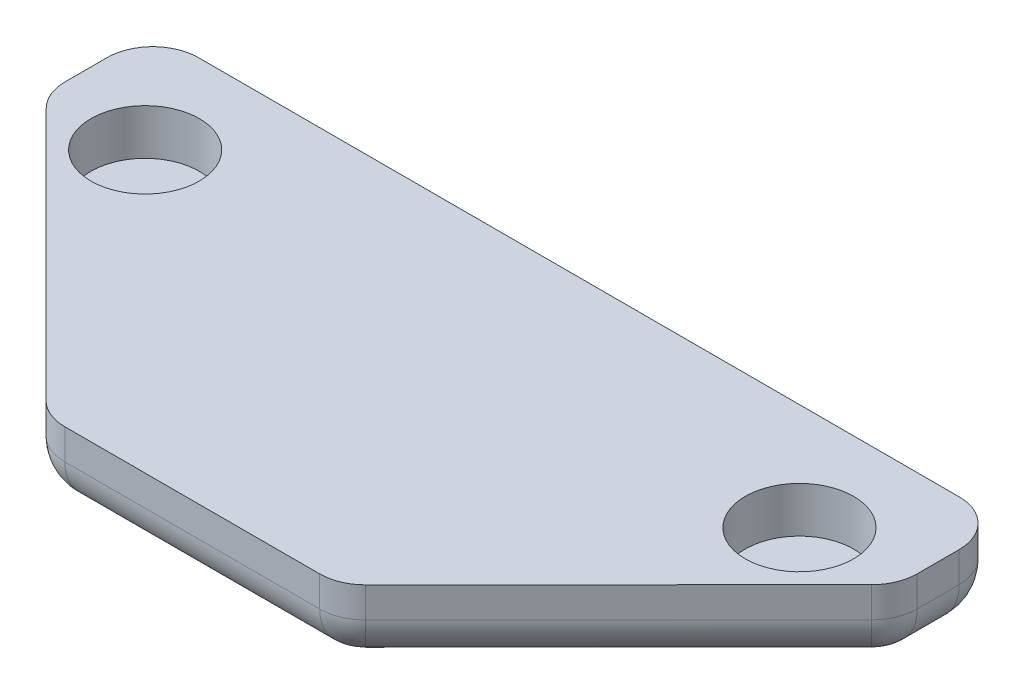
from build123d import *

# Parameters (mm, degrees)
BOSS_EXTRUDE1_DEPTH = 2.5
SKETCH2_R           = 1.78
CUT_EXTRUDE1_DEPTH  = 1.5
FILLET1_R           = 1.5


with BuildPart() as part:
    # Sketch1 → Boss-Extrude1 (new body)
    with BuildSketch(Plane(origin=(0, 0, 0), x_dir=(1, 0, 0), z_dir=(0, 1, 0))):
        Polygon((-21.216153836, 11.741903429), (-21.216153836, 8.241903429), (-12.024866066, -0.958096571), (-7.216153836, -0.958096571), (-7.216153836, 11.741903429), align=None)
    extrude(amount=BOSS_EXTRUDE1_DEPTH)

    # Sketch2 → Cut-Extrude1 (cut)
    with BuildSketch(Plane(origin=(0, 2.5, 0), x_dir=(1, 0, 0), z_dir=(0, 1, 0))):
        with Locations((-17.966153836, 8.241903429)):
            Circle(SKETCH2_R)
    extrude(amount=-CUT_EXTRUDE1_DEPTH, mode=Mode.SUBTRACT)

    # Fillet1
    fillet1_edges = [part.edges().sort_by_distance(p)[0] for p in [
        (-9.620509951, 0, 0.958096571),
        (-16.620509951, 0, -3.641903429),
        (-21.216153836, 0, -9.991903429),
        (-14.216153836, 0, -11.741903429),
        (-12.024866066, 1.25, 0.958096571),
        (-21.216153836, 1.25, -8.241903429),
        (-21.216153836, 1.25, -11.741903429),
    ]]
    fillet(fillet1_edges, radius=FILLET1_R)

    # Mirror1: part across plane


with BuildPart() as part_1:
    add(part.part)
    add(part.part.mirror(Plane(origin=(-7.216153836, 2.5, 0.958096571), x_dir=(0, 0, 1), z_dir=(-1, 0, 0))))


solid = part_1.part
